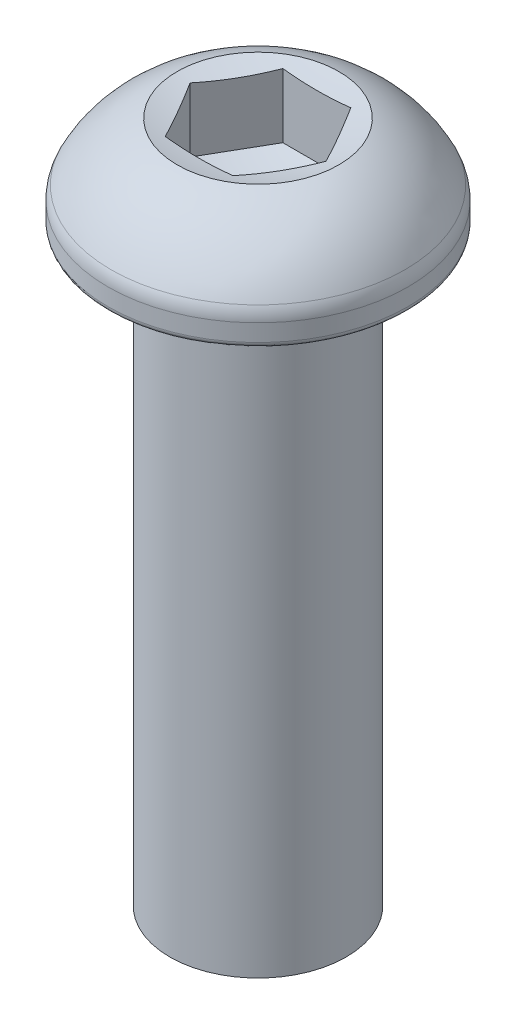
from build123d import *

# Parameters (mm, degrees)
FILLET1_R           = 0.2
FILLET2_R           = 1
SKETCH2_R           = 3
BOSS_EXTRUDE1_DEPTH = 20
CUT_EXTRUDE1_DEPTH  = 2.3


with BuildPart() as part:
    # Sketch1 → Revolve1 (revolve)
    with BuildSketch(Plane.XY):
        with BuildLine():
            Line((0, 0), (5.1, 0))
            Line((5.1, 0), (5.1, 1))
            ThreePointArc((5.1, 1), (4.1560785, 2.346833852), (2.75, 3.2))
            Line((2.75, 3.2), (0, 3.2))
            Line((0, 3.2), (0, 0))
        make_face()
    revolve(axis=Axis((0, 55, 0), (0, -1, 0)))

    # Fillet1
    fillet1_edges = [part.edges().sort_by_distance(p)[0] for p in [
        (-5.1, 0, 0),
    ]]
    fillet(fillet1_edges, radius=FILLET1_R)

    # Fillet2
    fillet2_edges = [part.edges().sort_by_distance(p)[0] for p in [
        (-5.1, 1, 0),
    ]]
    fillet(fillet2_edges, radius=FILLET2_R)

    # Sketch2 → Boss-Extrude1 (add)
    with BuildSketch(Plane.XZ):
        Circle(SKETCH2_R)
    extrude(amount=BOSS_EXTRUDE1_DEPTH)

    # Sketch6 → Revolve2 (revolve)
    with BuildSketch(Plane.XY):
        Polygon((0, 0), (0, 3.2), (2.75, 3.2), (4.9, 0), align=None)
    revolve(axis=Axis((0, 55, 0), (0, -1, 0)))

    # Sketch7 → Cut-Extrude1 (cut)
    with BuildSketch(Plane(origin=(0, 3.2, 0), x_dir=(1, 0, 0), z_dir=(0, 1, 0))):
        Polygon((1.154700538, -2), (2.309401077, 0), (1.154700538, 2), (-1.154700538, 2), (-2.309401077, 0), (-1.154700538, -2), align=None)
    extrude(amount=-CUT_EXTRUDE1_DEPTH, mode=Mode.SUBTRACT)

    # Sketch8 → Cut-Revolve1 (revolve, cut)
    with BuildSketch(Plane.XY):
        with BuildLine():
            Line((0, 0.9), (0, 0.5))
            Line((0, 0.5), (0.25, 0.5))
            ThreePointArc((0.25, 0.5), (1.298943849, 0.600925763), (2.309401077, 0.9))
            Line((2.309401077, 0.9), (0, 0.9))
        make_face()
    revolve(axis=Axis((0, 55, 0), (0, -1, 0)), mode=Mode.SUBTRACT)

    # Sketch9 → Cut-Revolve2 (revolve, cut)
    with BuildSketch(Plane.XY):
        with BuildLine():
            ThreePointArc((0, 2.814442262), (1.388448304, 2.911300775), (2.75, 3.2))
            Line((2.75, 3.2), (0, 3.2))
            Line((0, 3.2), (0, 2.814442262))
        make_face()
    revolve(axis=Axis((0, 55, 0), (0, -1, 0)), mode=Mode.SUBTRACT)


solid = part.part
